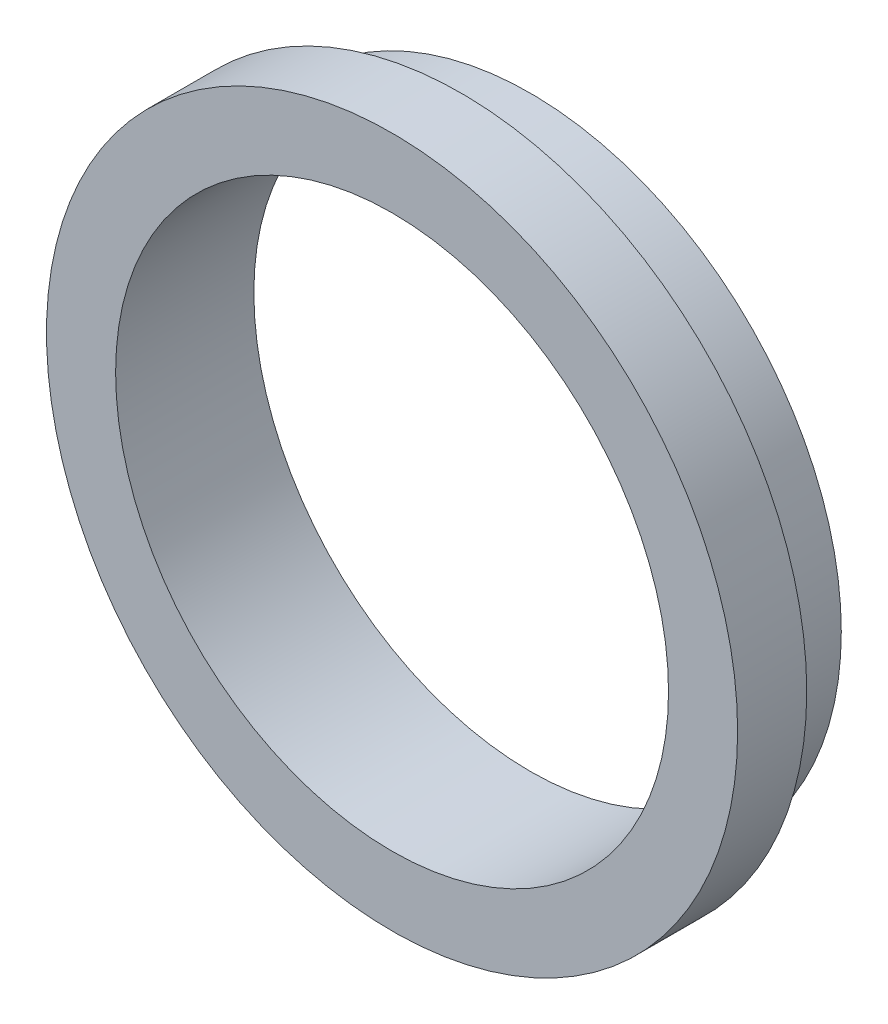
from build123d import *

# Parameters (mm, degrees)
SKETCH_1_R          = 4.5
EXTRUDE_1_DEPTH     = 1
SKETCH_2_R          = 5
EXTRUDE_2_DEPTH     = 1
SKETCH_3_R          = 4
CUT_EXTRUDE_1_DEPTH = 2


with BuildPart() as part:
    # 草图1 → 凸台-拉伸1 (new body)
    with BuildSketch(Plane.XY):
        Circle(SKETCH_1_R)
    extrude(amount=EXTRUDE_1_DEPTH)

    # 草图2 → 凸台-拉伸2 (add)
    with BuildSketch(Plane.XY.offset(1)):
        Circle(SKETCH_2_R)
    extrude(amount=EXTRUDE_2_DEPTH)

    # 草图3 → 切除-拉伸1 (cut)
    with BuildSketch(Plane(origin=(0, 0, 0), x_dir=(-1, 0, 0), z_dir=(0, 0, -1))):
        Circle(SKETCH_3_R)
    extrude(amount=-CUT_EXTRUDE_1_DEPTH, mode=Mode.SUBTRACT)


solid = part.part
